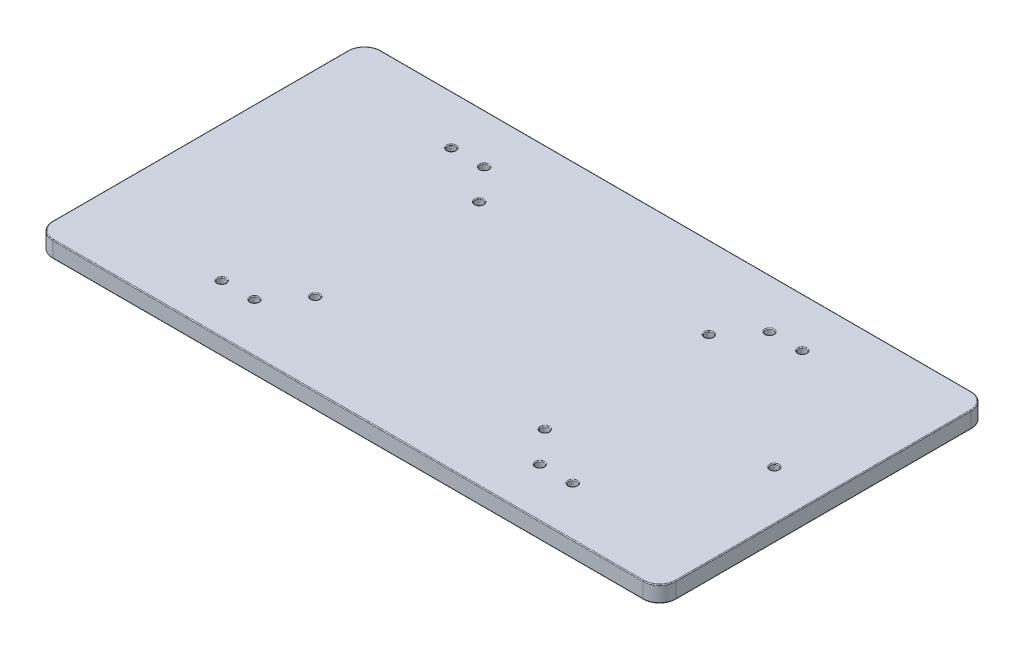
from build123d import *

# Parameters (mm, degrees)
SKETCH1_W           = 190
SKETCH1_H           = 100
SKETCH1_R           = 1.25
BOSS_EXTRUDE1_DEPTH = 5
FILLET1_R           = 5
FILLET2_R           = 0.25


with BuildPart() as part:
    # Sketch1 → Boss-Extrude1 (new body)
    with BuildSketch(Plane(origin=(0, 0, 0), x_dir=(1, 0, 0), z_dir=(0, 1, 0))):
        Rectangle(SKETCH1_W, SKETCH1_H)
        with Locations((-35, 25)):
            Circle(SKETCH1_R, mode=Mode.SUBTRACT)
        with Locations((35, 25)):
            Circle(SKETCH1_R, mode=Mode.SUBTRACT)
        with Locations((-35, -25)):
            Circle(SKETCH1_R, mode=Mode.SUBTRACT)
        with Locations((35, -25)):
            Circle(SKETCH1_R, mode=Mode.SUBTRACT)
        with Locations((80, 0)):
            Circle(SKETCH1_R, mode=Mode.SUBTRACT)
        with Locations((-53.5, -35)):
            Circle(SKETCH1_R, mode=Mode.SUBTRACT)
        with Locations((-43.5, -35)):
            Circle(SKETCH1_R, mode=Mode.SUBTRACT)
        with Locations((-43.5, 35)):
            Circle(SKETCH1_R, mode=Mode.SUBTRACT)
        with Locations((-53.5, 35)):
            Circle(SKETCH1_R, mode=Mode.SUBTRACT)
        with Locations((43.5, -35)):
            Circle(SKETCH1_R, mode=Mode.SUBTRACT)
        with Locations((53.5, -35)):
            Circle(SKETCH1_R, mode=Mode.SUBTRACT)
        with Locations((43.5, 35)):
            Circle(SKETCH1_R, mode=Mode.SUBTRACT)
        with Locations((53.5, 35)):
            Circle(SKETCH1_R, mode=Mode.SUBTRACT)
    extrude(amount=BOSS_EXTRUDE1_DEPTH)

    # Fillet1
    fillet1_edges = [part.edges().sort_by_distance(p)[0] for p in [
        (95, 2.5, 50),
        (-95, 2.5, 50),
        (-95, 2.5, -50),
        (95, 2.5, -50),
    ]]
    fillet(fillet1_edges, radius=FILLET1_R)

    # Fillet2
    fillet2_edges = [part.edges().sort_by_distance(p)[0] for p in [
        (-36.25, 0, -25),
        (-36.25, 5, -25),
        (33.75, 0, -25),
        (33.75, 5, -25),
        (-36.25, 0, 25),
        (-36.25, 5, 25),
        (33.75, 0, 25),
        (33.75, 5, 25),
        (78.75, 0, 0),
        (78.75, 5, 0),
        (-54.75, 0, 35),
        (-54.75, 5, 35),
        (-44.75, 0, 35),
        (-44.75, 5, 35),
        (-44.75, 0, -35),
        (-44.75, 5, -35),
        (-54.75, 0, -35),
        (-54.75, 5, -35),
        (42.25, 0, 35),
        (42.25, 5, 35),
        (52.25, 0, 35),
        (52.25, 5, 35),
        (42.25, 0, -35),
        (42.25, 5, -35),
        (52.25, 0, -35),
        (52.25, 5, -35),
        (95, 0, 0),
        (95, 5, 0),
        (0, 0, 50),
        (-95, 0, 0),
        (0, 0, -50),
        (-93.535533906, 0, 48.535533906),
        (93.535533906, 0, -48.535533906),
        (-93.535533906, 0, -48.535533906),
        (93.535533906, 0, 48.535533906),
        (0, 5, 50),
        (0, 5, -50),
        (-95, 5, 0),
        (-93.535533906, 5, 48.535533906),
        (93.535533906, 5, -48.535533906),
        (-93.535533906, 5, -48.535533906),
        (93.535533906, 5, 48.535533906),
    ]]
    fillet(fillet2_edges, radius=FILLET2_R)


solid = part.part
